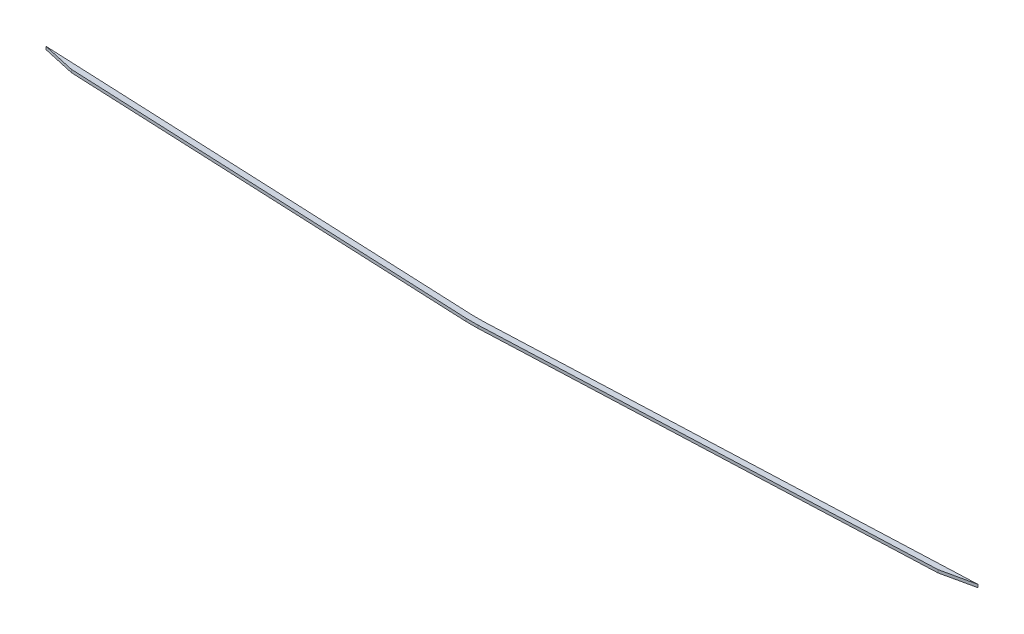
from build123d import *

# Parameters (mm, degrees)
EXTRUDE1_DEPTH = 1.5


with BuildPart() as part:
    # Sketch1 → Extrude1 (new body, symmetric)
    with BuildSketch(Plane(origin=(0, 0, 0), x_dir=(1, 0, 0), z_dir=(0, 1, 0))):
        Polygon((-6, 6), (-465, 26.220264317), (-431.302022404, 18.735771912), (-6, 0), (6, 0), (461.277824715, 18.813133253), (495, 26.20661157), (6, 6), align=None)
    extrude(amount=EXTRUDE1_DEPTH, both=True)


solid = part.part
